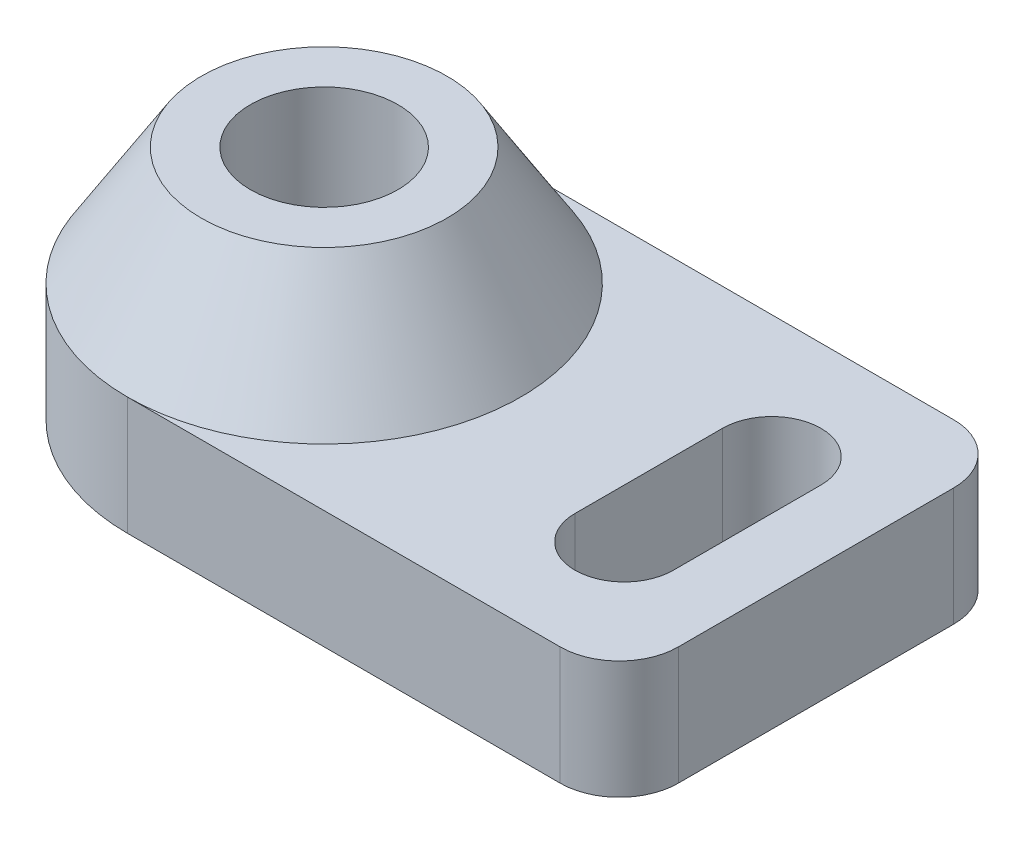
from build123d import *

# Parameters (mm, degrees)
Y_KSEKLIK_EKSTR_ZYON1_DEPTH = 6
IZIM2_R                     = 6.25
IZIM2_R_2                   = 3.75
Y_KSEKLIK_EKSTR_ZYON2_DEPTH = 6
KES_EKSTR_ZYON1_DEPTH       = 6
IZIM5_R                     = 3.75
KES_EKSTR_ZYON2_DEPTH       = 6
RADYUS1_R                   = 3
RADYUS2_R                   = 3


with BuildPart() as part:
    # Çizim1 → Yükseklik-Ekstrüzyon1 (new body)
    with BuildSketch(Plane(origin=(0, 0, 0), x_dir=(1, 0, 0), z_dir=(0, 1, 0))):
        with BuildLine():
            ThreePointArc((-25, 20), (-35, 10), (-25, 0))
            Line((-25, 0), (-25, 20))
        make_face()
        with BuildLine():
            Line((-25, 20), (-25, 0))
            ThreePointArc((-25, 0), (-17.928932188, 2.928932188), (-15, 10))
            ThreePointArc((-15, 10), (-17.928932188, 17.071067812), (-25, 20))
        make_face()
        with BuildLine():
            Line((-25, 0), (0, 0))
            Line((0, 0), (0, 20))
            Line((0, 20), (-25, 20))
            ThreePointArc((-25, 20), (-17.928932188, 17.071067812), (-15, 10))
            ThreePointArc((-15, 10), (-17.928932188, 2.928932188), (-25, 0))
        make_face()
    extrude(amount=Y_KSEKLIK_EKSTR_ZYON1_DEPTH)

    # Çizim2 → Yükseklik-Ekstrüzyon2 (add)
    with BuildSketch(Plane(origin=(0, 6, 0), x_dir=(1, 0, 0), z_dir=(0, 1, 0))):
        with Locations((-25, 10)):
            Circle(IZIM2_R)
        with Locations((-25, 10)):
            Circle(IZIM2_R_2, mode=Mode.SUBTRACT)
    extrude(amount=Y_KSEKLIK_EKSTR_ZYON2_DEPTH)

    # Çizim4 → Kes-Ekstrüzyon1 (cut)
    with BuildSketch(Plane(origin=(0, 6, 0), x_dir=(1, 0, 0), z_dir=(0, 1, 0))):
        with BuildLine():
            Line((-3.5, 13.75), (-3.5, 6.25))
            ThreePointArc((-3.5, 6.25), (-6, 3.75), (-8.5, 6.25))
            Line((-8.5, 6.25), (-8.5, 13.75))
            ThreePointArc((-8.5, 13.75), (-6, 16.25), (-3.5, 13.75))
        make_face()
    extrude(amount=-KES_EKSTR_ZYON1_DEPTH, mode=Mode.SUBTRACT)

    # Çizim5 → Kes-Ekstrüzyon2 (cut)
    with BuildSketch(Plane(origin=(0, 6, 0), x_dir=(1, 0, 0), z_dir=(0, 1, 0))):
        with Locations((-25, 10)):
            Circle(IZIM5_R)
    extrude(amount=-KES_EKSTR_ZYON2_DEPTH, mode=Mode.SUBTRACT)

    # Radyus1
    radyus1_edges = [part.edges().sort_by_distance(p)[0] for p in [
        (0, 3, 0),
    ]]
    fillet(radyus1_edges, radius=RADYUS1_R)

    # Radyus2
    radyus2_edges = [part.edges().sort_by_distance(p)[0] for p in [
        (0, 3, -20),
    ]]
    fillet(radyus2_edges, radius=RADYUS2_R)

    # Çizim6 → Döndür1 (revolve)
    with BuildSketch(Plane(origin=(-25, 0, 0), x_dir=(0, 0, -1), z_dir=(1, 0, 0))):
        Polygon((3.75, 12), (0, 6), (3.75, 6), align=None)
    revolve(axis=Axis((-25, 12, -10), (0, -1, 0)))


solid = part.part
